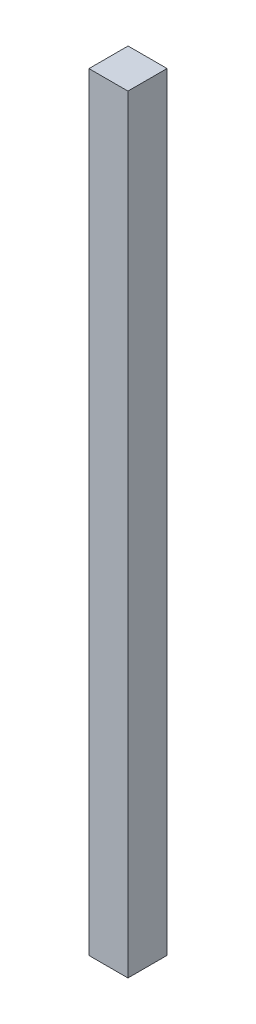
from build123d import *

# Parameters (mm, degrees)
SKETCH1_W           = 34.798
SKETCH1_H           = 34.925
BOSS_EXTRUDE1_DEPTH = 685.8


with BuildPart() as part:
    # Sketch1 → Boss-Extrude1 (new body)
    with BuildSketch(Plane(origin=(0, 0, 0), x_dir=(1, 0, 0), z_dir=(0, 1, 0))):
        Rectangle(SKETCH1_W, SKETCH1_H)
    extrude(amount=BOSS_EXTRUDE1_DEPTH)


solid = part.part
